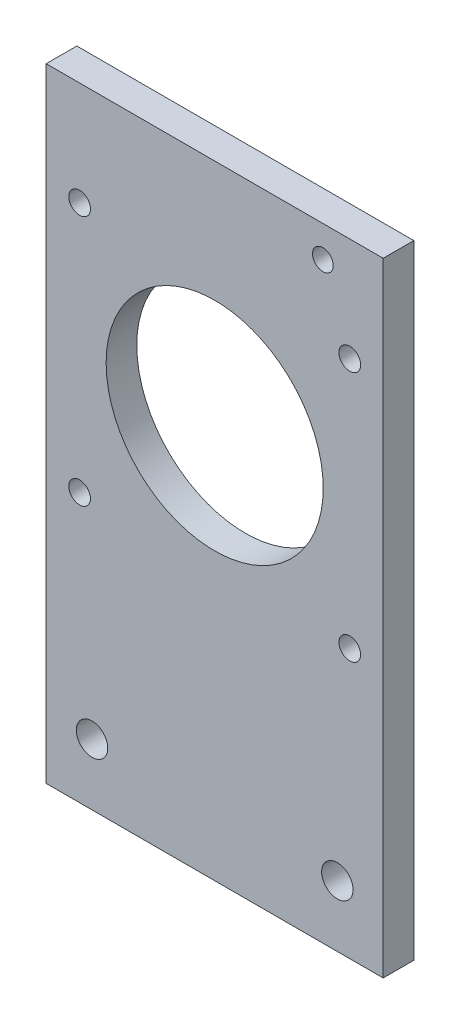
from build123d import *

# Parameters (mm, degrees)
SKETCH2_R               = 22.5
BOSS_EXTRUDE1_DEPTH     = 3.175
SKETCH3_R               = 3.25755
SKETCH3_R_2             = 2.15
CUT_EXTRUDE1_DEPTH      = 1
CUT_EXTRUDE1_DEPTH_BACK = 7.35
SKETCH4_R               = 2.25
CUT_EXTRUDE2_DEPTH      = 1
CUT_EXTRUDE2_DEPTH_BACK = 7.35


with BuildPart() as part:
    # Sketch2 → Boss-Extrude1 (new body, symmetric)
    with BuildSketch(Plane.XY):
        Polygon((-34.925, 0), (34.925, 0), (34.925, 81.7), (34.925, 114.2), (34.925, 129.2), (-34.925, 129.2), (-34.925, 114.2), (-34.925, 81.7), align=None)
        with Locations((0, 81.7)):
            Circle(SKETCH2_R, mode=Mode.SUBTRACT)
    extrude(amount=BOSS_EXTRUDE1_DEPTH, both=True)

    # Sketch3 → Cut-Extrude1 (cut, two sides)
    with BuildSketch(Plane.XY.offset(3.175)) as cut_extrude1_sk:
        with Locations((-25.425, 12.7)):
            Circle(SKETCH3_R)
        with Locations((25.425, 12.7)):
            Circle(SKETCH3_R)
        with Locations((22.425, 122.7)):
            Circle(SKETCH3_R_2)
    extrude(amount=CUT_EXTRUDE1_DEPTH, mode=Mode.SUBTRACT)
    extrude(cut_extrude1_sk.sketch, amount=-CUT_EXTRUDE1_DEPTH_BACK, mode=Mode.SUBTRACT)

    # Sketch4 → Cut-Extrude2 (cut, two sides)
    with BuildSketch(Plane(origin=(0, 0, -3.175), x_dir=(-1, 0, 0), z_dir=(0, 0, -1))) as cut_extrude2_sk:
        with Locations((-28, 107.7)):
            Circle(SKETCH4_R)
        with Locations((28, 107.7)):
            Circle(SKETCH4_R)
        with Locations((-28, 55.7)):
            Circle(SKETCH4_R)
        with Locations((28, 55.7)):
            Circle(SKETCH4_R)
    extrude(amount=CUT_EXTRUDE2_DEPTH, mode=Mode.SUBTRACT)
    extrude(cut_extrude2_sk.sketch, amount=-CUT_EXTRUDE2_DEPTH_BACK, mode=Mode.SUBTRACT)


solid = part.part
